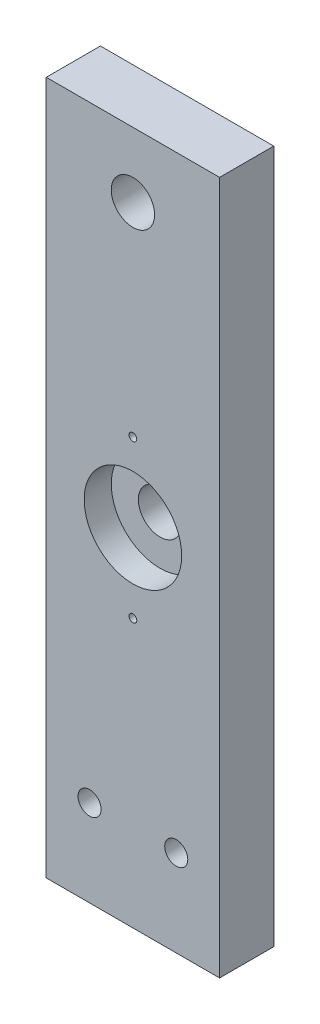
from build123d import *

# Parameters (mm, degrees)
SKETCH1_W                 = 50.8
SKETCH1_H                 = 203.2
BOSS_EXTRUDE1_DEPTH       = 15.875
F_1_4_CLEARANCE_HOLE1_D   = 6.7564
SKETCH5_R                 = 6.35
CUT_EXTRUDE1_DEPTH        = 16.875
SKETCH6_R                 = 14.2875
CUT_EXTRUDE2_DEPTH        = 7.9375
F_4_40_TAPPED_HOLE1_D     = 2.2606
F_4_40_TAPPED_HOLE1_DEPTH = 7.62
F_4_40_TAPPED_HOLE1_TIP   = 0.679152758


with BuildPart() as part:
    # Sketch1 → Boss-Extrude1 (new body)
    with BuildSketch(Plane.XY):
        with Locations((0, 76.2)):
            Rectangle(SKETCH1_W, SKETCH1_H)
    extrude(amount=BOSS_EXTRUDE1_DEPTH)

    # 1/4 Clearance Hole1 (through all)
    with Locations(Plane.XY.offset(15.875)):
        with Locations((12.7, 0), (-12.7, 0)):
            Hole(F_1_4_CLEARANCE_HOLE1_D / 2)

    # Sketch5 → Cut-Extrude1 (cut, through all)
    with BuildSketch(Plane(origin=(0, 0, 0), x_dir=(-1, 0, 0), z_dir=(0, 0, -1))):
        with Locations((0, 158.75)):
            Circle(SKETCH5_R)
        with Locations((0, 76.2)):
            Circle(SKETCH5_R)
    extrude(amount=-CUT_EXTRUDE1_DEPTH, mode=Mode.SUBTRACT)

    # Sketch6 → Cut-Extrude2 (cut)
    with BuildSketch(Plane.XY.offset(15.875)):
        with Locations((0, 76.2)):
            Circle(SKETCH6_R)
    extrude(amount=-CUT_EXTRUDE2_DEPTH, mode=Mode.SUBTRACT)

    # #4-40 Tapped Hole1
    with Locations(Plane.XY.offset(15.875)):
        with Locations((0, 99.187), (0, 53.213)):
            Hole(F_4_40_TAPPED_HOLE1_D / 2, depth=F_4_40_TAPPED_HOLE1_DEPTH)
            with Locations((0, 0, -(F_4_40_TAPPED_HOLE1_DEPTH + F_4_40_TAPPED_HOLE1_TIP / 2))):  # 118° drill point
                Cone(0, F_4_40_TAPPED_HOLE1_D / 2, F_4_40_TAPPED_HOLE1_TIP, mode=Mode.SUBTRACT)


solid = part.part
